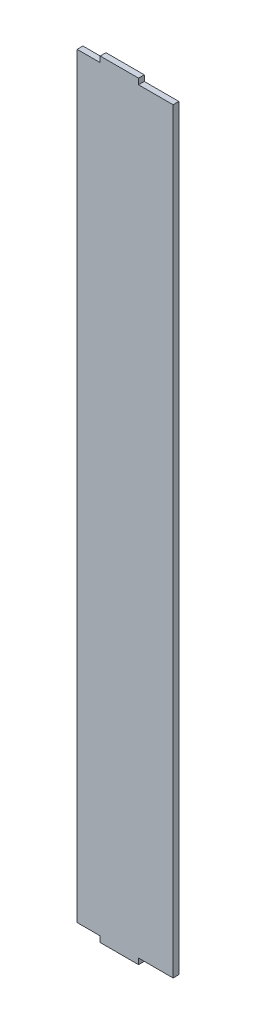
from build123d import *

# Parameters (mm, degrees)
SALIENTE_EXTRUIR2_DEPTH = 3


with BuildPart() as part:
    # Croquis1 → Saliente-Extruir2 (new body)
    with BuildSketch(Plane.XY):
        Polygon((32, -3), (32, 0), (50, 0), (50, 394), (32, 394), (32, 397), (12, 397), (12, 394), (0, 394), (0, 0), (12, 0), (12, -3), align=None)
    extrude(amount=SALIENTE_EXTRUIR2_DEPTH)


solid = part.part
